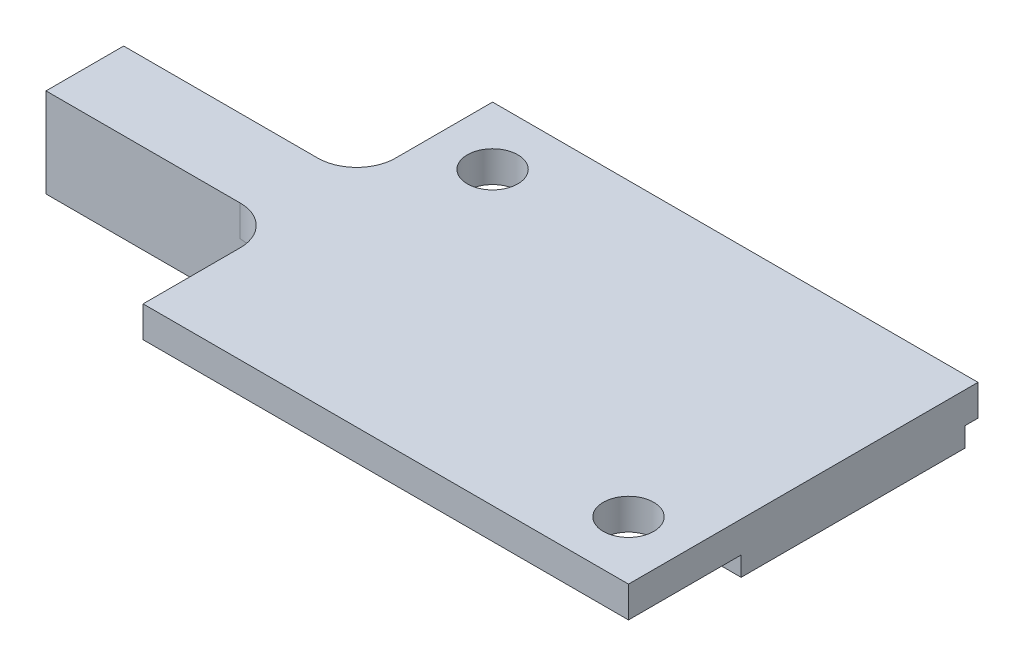
from build123d import *

# Parameters (mm, degrees)
BOSS_EXTRUDE1_DEPTH = 1.6
BOSS_EXTRUDE2_DEPTH = 12
SKETCH3_R           = 1.3
CUT_EXTRUDE1_DEPTH  = 1.6
FILLET1_R           = 2
BOSS_EXTRUDE3_DEPTH = 1


with BuildPart() as part:
    # Sketch1 → Boss-Extrude1 (new body)
    with BuildSketch(Plane(origin=(0, 0, 0), x_dir=(1, 0, 0), z_dir=(0, 1, 0))):
        Polygon((0, 11), (0, 18), (25, 18), (25, 0), (0, 0), (0, 7), (-12, 7), (-12, 11), align=None)
    extrude(amount=BOSS_EXTRUDE1_DEPTH)

    # Sketch2 → Boss-Extrude2 (add)
    with BuildSketch(Plane.ZY.offset(12)):
        with BuildLine():
            Line((-7, -3), (-7, 0))
            Line((-7, 0), (-11, 0))
            Line((-11, 0), (-11, -3))
            ThreePointArc((-11, -3), (-9, -1), (-7, -3))
        make_face()
    extrude(amount=-BOSS_EXTRUDE2_DEPTH)

    # Sketch3 → Cut-Extrude1 (cut)
    with BuildSketch(Plane(origin=(0, 1.6, 0), x_dir=(1, 0, 0), z_dir=(0, 1, 0))):
        with Locations((3, 15)):
            Circle(SKETCH3_R)
        with Locations((22, 3)):
            Circle(SKETCH3_R)
    extrude(amount=-CUT_EXTRUDE1_DEPTH, mode=Mode.SUBTRACT)

    # Fillet1
    fillet1_edges = [part.edges().sort_by_distance(p)[0] for p in [
        (0, 0.8, -7),
        (0, 0.8, -11),
    ]]
    fillet(fillet1_edges, radius=FILLET1_R)

    # Sketch4 → Boss-Extrude3 (add)
    with BuildSketch(Plane.XZ):
        Polygon((25, -5.8), (25, -17.33), (20.285605544, -15.019808468), (23, -11.947014506), (23, -5.8), align=None)
    extrude(amount=BOSS_EXTRUDE3_DEPTH)


solid = part.part
